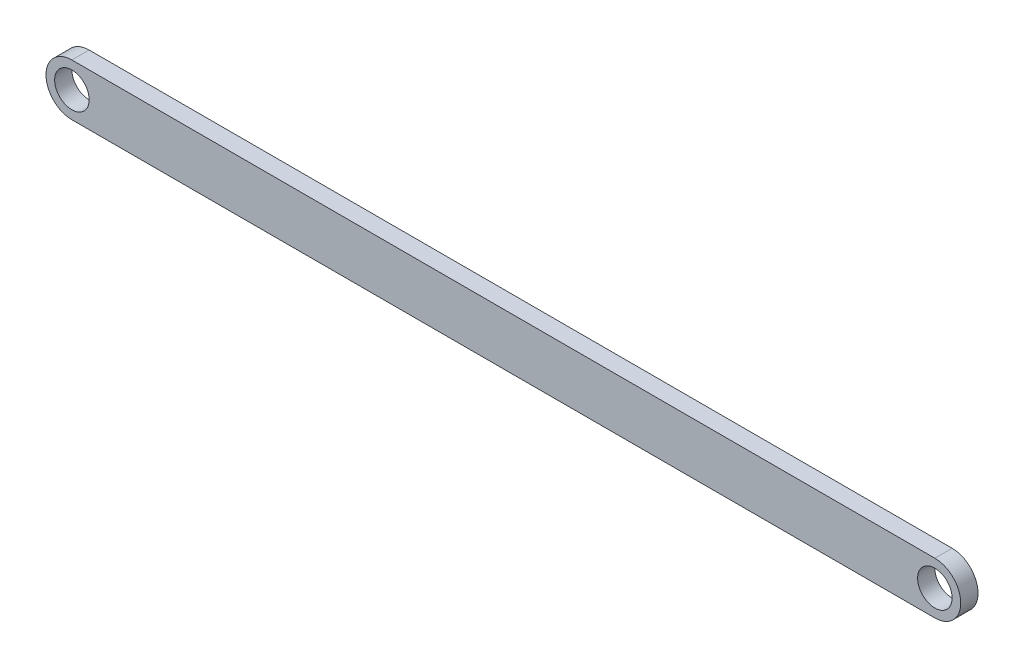
from build123d import *

# Parameters (mm, degrees)
SKETCH_1_R      = 2
EXTRUDE_2_DEPTH = 2


with BuildPart() as part:
    # 草图1 → 凸台-拉伸2 (new body)
    with BuildSketch(Plane.XY):
        with BuildLine():
            Line((-51.955335916, -3), (48.044664084, -3))
            ThreePointArc((48.044664084, -3), (51.044664084, 0), (48.044664084, 3))
            Line((48.044664084, 3), (-51.955335916, 3))
            ThreePointArc((-51.955335916, 3), (-54.955335916, 0), (-51.955335916, -3))
        make_face()
        with Locations((48.044664084, 0)):
            Circle(SKETCH_1_R, mode=Mode.SUBTRACT)
        with Locations((-51.955335916, 0)):
            Circle(SKETCH_1_R, mode=Mode.SUBTRACT)
    extrude(amount=EXTRUDE_2_DEPTH)


solid = part.part
